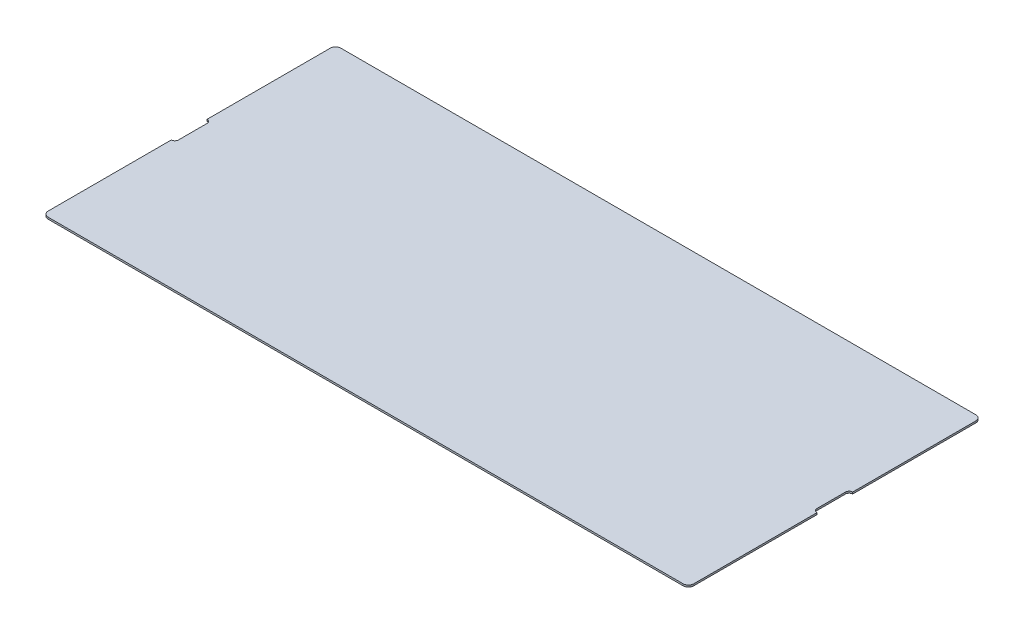
from build123d import *

# Parameters (mm, degrees)
SHAPE_DEPTH = 0.5


with BuildPart() as part:
    # Sketch1 → Shape (new body)
    with BuildSketch(Plane(origin=(0, 0, 0), x_dir=(1, 0, 0), z_dir=(0, 1, 0))):
        with BuildLine():
            Line((88.7, 40.9), (-88.7, 40.9))
            ThreePointArc((-88.7, 40.9), (-89.760660172, 40.460660172), (-90.2, 39.4))
            Line((-90.2, 39.4), (-90.2, 5))
            ThreePointArc((-90.2, 5), (-89.492893219, 4.707106781), (-89.2, 4))
            Line((-89.2, 4), (-89.2, -4))
            ThreePointArc((-89.2, -4), (-89.492893219, -4.707106781), (-90.2, -5))
            Line((-90.2, -5), (-90.2, -39.4))
            ThreePointArc((-90.2, -39.4), (-89.760660172, -40.460660172), (-88.7, -40.9))
            Line((-88.7, -40.9), (88.7, -40.9))
            ThreePointArc((88.7, -40.9), (89.760660172, -40.460660172), (90.2, -39.4))
            Line((90.2, -39.4), (90.2, -5))
            ThreePointArc((90.2, -5), (89.492893219, -4.707106781), (89.2, -4))
            Line((89.2, -4), (89.2, 4))
            ThreePointArc((89.2, 4), (89.492893219, 4.707106781), (90.2, 5))
            Line((90.2, 5), (90.2, 39.4))
            ThreePointArc((90.2, 39.4), (89.760660172, 40.460660172), (88.7, 40.9))
        make_face()
    extrude(amount=SHAPE_DEPTH)


solid = part.part
